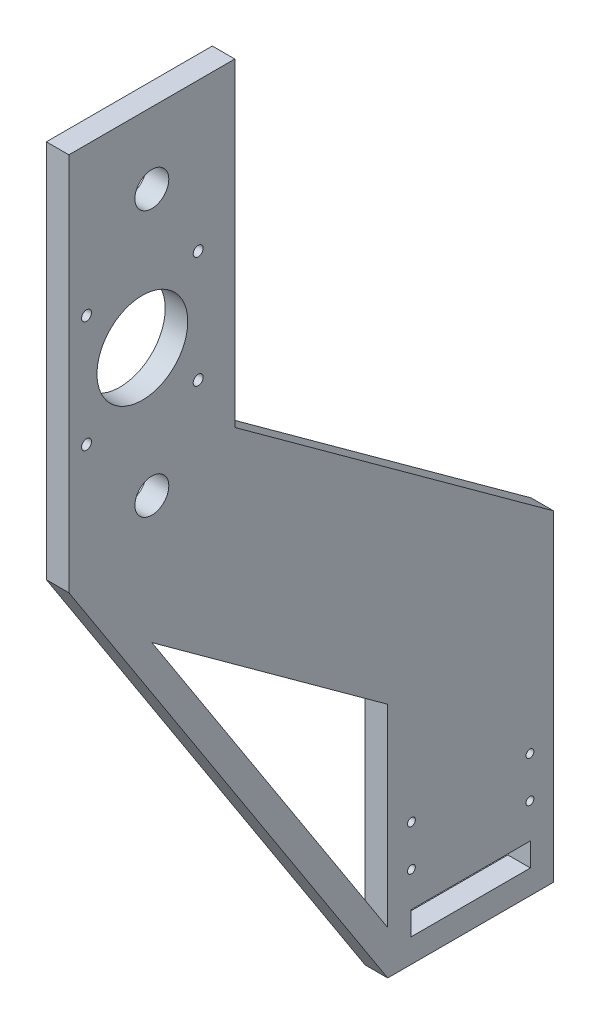
from build123d import *

# Parameters (mm, degrees)
SKETCH1_R           = 7.15
SKETCH1_R_2         = 19.15
SKETCH1_W           = 50.4
SKETCH1_H           = 9.9
BOSS_EXTRUDE1_DEPTH = 9.5
M4_TAPPED_HOLE1_D   = 3.3
M5_TAPPED_HOLE2_D   = 4.2


with BuildPart() as part:
    # Sketch1 → Boss-Extrude1 (new body)
    with BuildSketch(Plane(origin=(0, 0, 0), x_dir=(0, 0, -1), z_dir=(1, 0, 0))):
        Polygon((0, 0), (70, 0), (70, 135.667122158), (-64.5, 233.385504136), (-64.5, 368), (-134.5, 368), (-134.5, 208), align=None)
        with Locations((-99.5, 338)):
            Circle(SKETCH1_R, mode=Mode.SUBTRACT)
        with Locations((-99.5, 226)):
            Circle(SKETCH1_R, mode=Mode.SUBTRACT)
        with Locations((-103.5, 282)):
            Circle(SKETCH1_R_2, mode=Mode.SUBTRACT)
        Polygon((-99.5, 172.289806742), (0, 100), (0, 18.416200794), align=None, mode=Mode.SUBTRACT)
        with Locations((35, 15.05)):
            Rectangle(SKETCH1_W, SKETCH1_H, mode=Mode.SUBTRACT)
    extrude(amount=BOSS_EXTRUDE1_DEPTH)

    # M4 Tapped Hole1 (through all)
    with Locations(Plane(origin=(9.5, 0, 0), x_dir=(0, 0, -1), z_dir=(1, 0, 0))):
        with Locations((10, 34.7), (10, 52), (60, 52), (60, 34.7)):
            Hole(M4_TAPPED_HOLE1_D / 2)

    # M5 Tapped Hole2 (through all)
    with Locations(Plane(origin=(9.5, 0, 0), x_dir=(0, 0, -1), z_dir=(1, 0, 0))):
        with Locations((-127.05, 305.55), (-79.95, 305.55), (-79.95, 258.45), (-127.05, 258.45)):
            Hole(M5_TAPPED_HOLE2_D / 2)


solid = part.part
